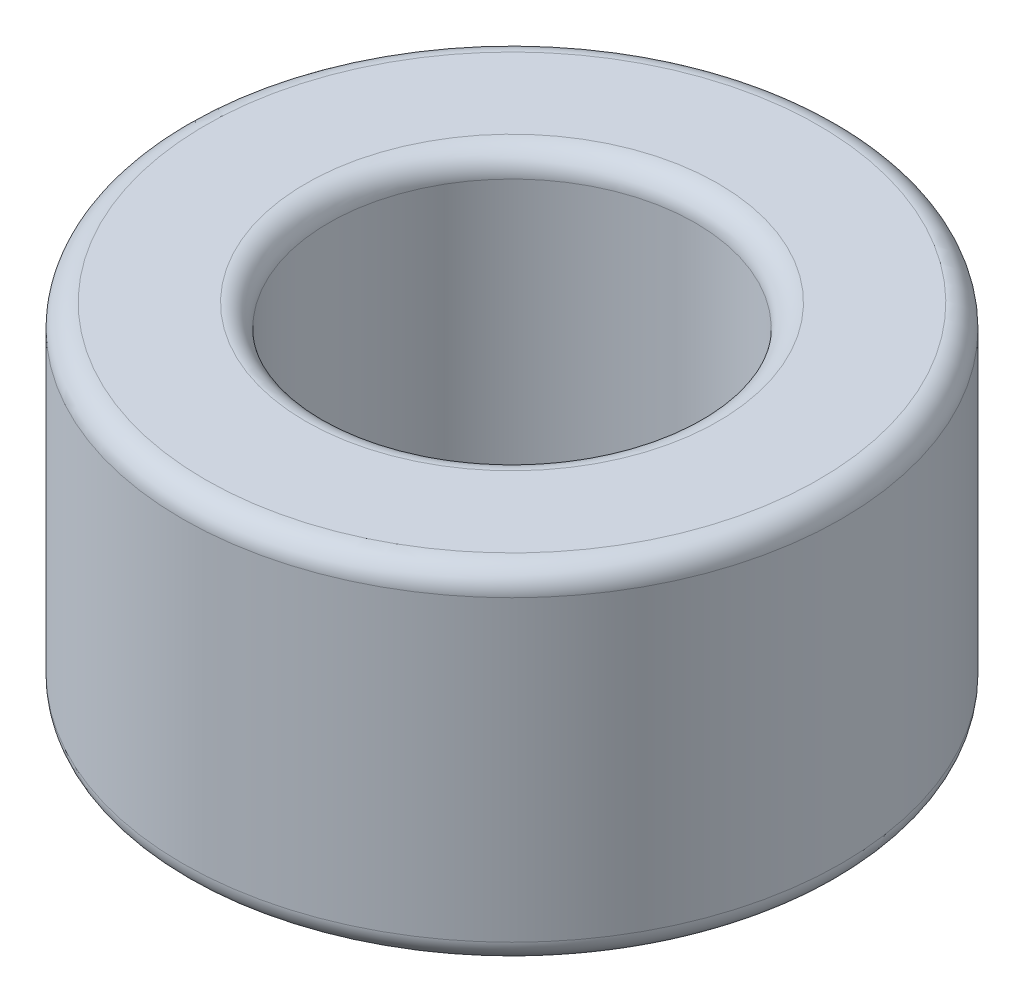
from build123d import *

# Parameters (mm, degrees)
SKETCH1_R           = 2.875
SKETCH1_R_2         = 1.6
BOSS_EXTRUDE1_DEPTH = 3
FILLET1_R           = 0.1984375


with BuildPart() as part:
    # Sketch1 → Boss-Extrude1 (new body)
    with BuildSketch(Plane(origin=(0, 0, 0), x_dir=(1, 0, 0), z_dir=(0, 1, 0))):
        Circle(SKETCH1_R)
        Circle(SKETCH1_R_2, mode=Mode.SUBTRACT)
    extrude(amount=BOSS_EXTRUDE1_DEPTH)

    # Fillet1
    fillet1_edges = [part.edges().sort_by_distance(p)[0] for p in [
        (-2.875, 0, 0),
        (-2.875, 3, 0),
        (-1.6, 0, 0),
        (-1.6, 3, 0),
    ]]
    fillet(fillet1_edges, radius=FILLET1_R)


solid = part.part
